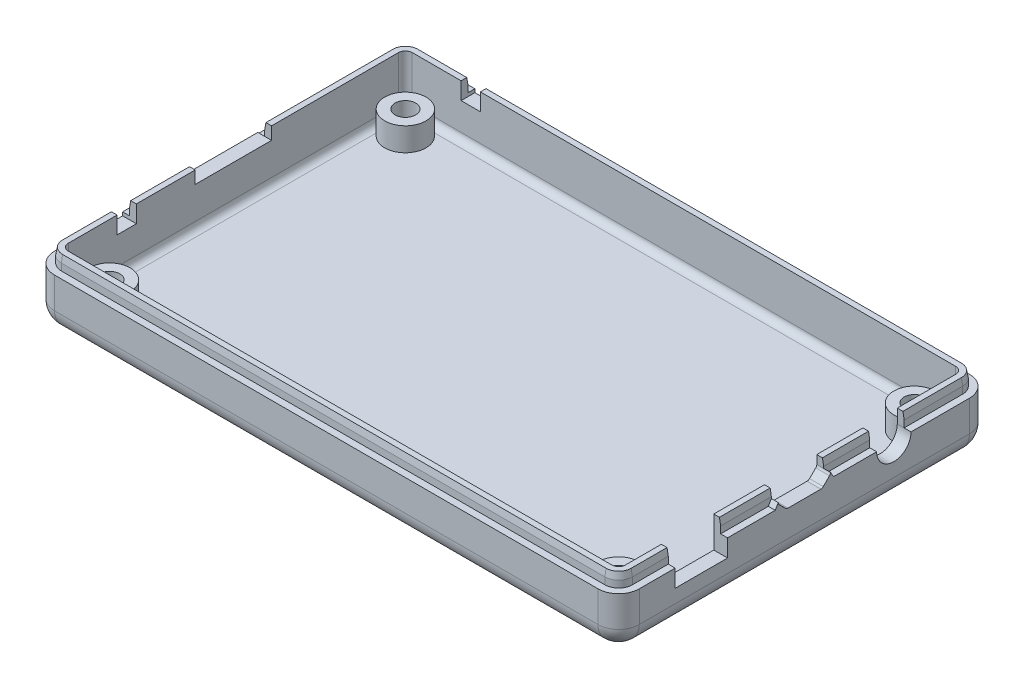
from build123d import *
from OCP.BRepFilletAPI import BRepFilletAPI_MakeChamfer

# Parameters (mm, degrees)
SKETCH_1_W                  = 85
SKETCH_1_H                  = 54
EXTRUDE_576_DEPTH           = 7.5
FILLET_627_R                = 3
CUT_EXTRUDE_1389_DEPTH      = 5.5
FILLET_1467_R               = 1
EXTRUDE_2395_DEPTH          = 2
CHAMFER_2448_SIZE           = 1
CHAMFER_2448_SIZE2          = 0.176326981
SKETCH_16_R                 = 2.5
CUT_EXTRUDE_2683_DEPTH      = 5
SKETCH_19_W                 = 7.62
SKETCH_19_H                 = 5.08
CUT_EXTRUDE_3124_DEPTH      = 10
SKETCH_21_W                 = 11.1
SKETCH_21_H                 = 1.1
CUT_EXTRUDE_2_DEPTH         = 10
SKETCH_22_W                 = 2.8
SKETCH_22_H                 = 1.2
CUT_EXTRUDE_3_DEPTH         = 10
CUT_EXTRUDE_5_DEPTH         = 10
SKETCH_30_W                 = 11.1
SKETCH_30_H                 = 0.725
SKETCH_30_W_2               = 2.8
SKETCH_30_H_2               = 1.3
CUT_EXTRUDE_6_DEPTH         = 1
EXTRUDE_2_DEPTH             = 1
EXTRUDE_3_DEPTH             = 1
CUT_EXTRUDE_START           = -1
SKETCH_31_W                 = 7.6
SKETCH_31_H                 = 0.55
SKETCH_31_W_2               = 5
SKETCH_31_H_2               = 2
CUT_EXTRUDE_7_DEPTH         = 1
SKETCH_32_W                 = 2.8
SKETCH_32_H                 = 1.2
CUT_EXTRUDE_8_DEPTH         = 10
SKETCH_33_W                 = 2.8
SKETCH_33_H                 = 1.3
CUT_EXTRUDE_9_DEPTH         = 2
SKETCH_34_R                 = 3
SKETCH_34_R_2               = 1.5
EXTRUDE_4_DEPTH             = 3.4
PATTERN_LINEAR_1_COUNT      = 2
PATTERN_LINEAR_1_PITCH      = 74
PATTERN_LINEAR_1_COUNT_DIR2 = 2
PATTERN_LINEAR_1_PITCH_DIR2 = 43


with BuildPart() as part:
    # 草图1 → Extrude 576 (new body)
    with BuildSketch(Plane(origin=(0, 0, 0), x_dir=(1, 0, 0), z_dir=(0, 1, 0))):
        Rectangle(SKETCH_1_W, SKETCH_1_H)
    extrude(amount=EXTRUDE_576_DEPTH)

    # Fillet 627
    fillet_627_edges = [part.edges().sort_by_distance(p)[0] for p in [
        (0, 0, 27),
        (-42.5, 0, 0),
        (0, 0, -27),
        (42.5, 0, 0),
        (42.5, 3.75, 27),
        (-42.5, 3.75, 27),
        (-42.5, 3.75, -27),
        (42.5, 3.75, -27),
    ]]
    fillet(fillet_627_edges, radius=FILLET_627_R)

    # 草图14 → Cut-Extrude 1389 (cut)
    with BuildSketch(Plane(origin=(0, 7.5, 0), x_dir=(1, 0, 0), z_dir=(0, 1, 0))):
        with BuildLine():
            Line((-39.5, -25), (39.5, -25))
            ThreePointArc((39.5, -25), (40.207106781, -24.707106781), (40.5, -24))
            Line((40.5, -24), (40.5, 24))
            ThreePointArc((40.5, 24), (40.207106781, 24.707106781), (39.5, 25))
            Line((39.5, 25), (-39.5, 25))
            ThreePointArc((-39.5, 25), (-40.207106781, 24.707106781), (-40.5, 24))
            Line((-40.5, 24), (-40.5, -24))
            ThreePointArc((-40.5, -24), (-40.207106781, -24.707106781), (-39.5, -25))
        make_face()
    extrude(amount=-CUT_EXTRUDE_1389_DEPTH, mode=Mode.SUBTRACT)

    # Fillet 1467
    fillet_1467_edges = [part.edges().sort_by_distance(p)[0] for p in [
        (40.207106781, 2, 24.707106781),
        (0, 2, 25),
        (-40.207106781, 2, 24.707106781),
        (-40.5, 2, 0),
        (-40.207106781, 2, -24.707106781),
        (0, 2, -25),
        (40.207106781, 2, -24.707106781),
        (40.5, 2, 0),
    ]]
    fillet(fillet_1467_edges, radius=FILLET_1467_R)

    # 草图15 → Extrude 2395 (add)
    with BuildSketch(Plane(origin=(0, 7.5, 0), x_dir=(1, 0, 0), z_dir=(0, 1, 0))):
        with BuildLine():
            Line((-39.5, -26), (39.5, -26))
            ThreePointArc((39.5, -26), (40.914213562, -25.414213562), (41.5, -24))
            Line((41.5, -24), (41.5, 24))
            ThreePointArc((41.5, 24), (40.914213562, 25.414213562), (39.5, 26))
            Line((39.5, 26), (-39.5, 26))
            ThreePointArc((-39.5, 26), (-40.914213562, 25.414213562), (-41.5, 24))
            Line((-41.5, 24), (-41.5, -24))
            ThreePointArc((-41.5, -24), (-40.914213562, -25.414213562), (-39.5, -26))
        make_face()
        with BuildLine():
            Line((-39.5, -25), (39.5, -25))
            ThreePointArc((39.5, -25), (40.207106781, -24.707106781), (40.5, -24))
            Line((40.5, -24), (40.5, 24))
            ThreePointArc((40.5, 24), (40.207106781, 24.707106781), (39.5, 25))
            Line((39.5, 25), (-39.5, 25))
            ThreePointArc((-39.5, 25), (-40.207106781, 24.707106781), (-40.5, 24))
            Line((-40.5, 24), (-40.5, -24))
            ThreePointArc((-40.5, -24), (-40.207106781, -24.707106781), (-39.5, -25))
        make_face(mode=Mode.SUBTRACT)
    extrude(amount=EXTRUDE_2395_DEPTH)

    # Chamfer 2448: one chamfer whose edges measure the first distance from different faces: ONE call of the kernel's chamfer builder (chamfer() names one face for all edges)
    chamfer_2448_edges_1 = [part.edges().sort_by_distance(p)[0] for p in [
        (-40.914213562, 9.5, 25.414213562),
    ]]
    chamfer_2448_side_1 = [part.faces().sort_by_distance(p)[0] for p in [
        (-40.914213562, 8.5, 25.414213562),
    ]]
    chamfer_2448_edges_2 = [part.edges().sort_by_distance(p)[0] for p in [
        (0, 9.5, 26),
    ]]
    chamfer_2448_side_2 = [part.faces().sort_by_distance(p)[0] for p in [
        (0, 8.5, 26),
    ]]
    chamfer_2448_edges_3 = [part.edges().sort_by_distance(p)[0] for p in [
        (40.914213562, 9.5, 25.414213562),
    ]]
    chamfer_2448_side_3 = [part.faces().sort_by_distance(p)[0] for p in [
        (40.914213562, 8.5, 25.414213562),
    ]]
    chamfer_2448_edges_4 = [part.edges().sort_by_distance(p)[0] for p in [
        (41.5, 9.5, 0),
    ]]
    chamfer_2448_side_4 = [part.faces().sort_by_distance(p)[0] for p in [
        (41.5, 8.5, 0),
    ]]
    chamfer_2448_edges_5 = [part.edges().sort_by_distance(p)[0] for p in [
        (40.914213562, 9.5, -25.414213562),
    ]]
    chamfer_2448_side_5 = [part.faces().sort_by_distance(p)[0] for p in [
        (40.914213562, 8.5, -25.414213562),
    ]]
    chamfer_2448_edges_6 = [part.edges().sort_by_distance(p)[0] for p in [
        (0, 9.5, -26),
    ]]
    chamfer_2448_side_6 = [part.faces().sort_by_distance(p)[0] for p in [
        (0, 8.5, -26),
    ]]
    chamfer_2448_edges_7 = [part.edges().sort_by_distance(p)[0] for p in [
        (-40.914213562, 9.5, -25.414213562),
    ]]
    chamfer_2448_side_7 = [part.faces().sort_by_distance(p)[0] for p in [
        (-40.914213562, 8.5, -25.414213562),
    ]]
    chamfer_2448_edges_8 = [part.edges().sort_by_distance(p)[0] for p in [
        (-41.5, 9.5, 0),
    ]]
    chamfer_2448_side_8 = [part.faces().sort_by_distance(p)[0] for p in [
        (-41.5, 8.5, 0),
    ]]
    chamfer_2448 = BRepFilletAPI_MakeChamfer(part.part.solid().wrapped)
    for e in chamfer_2448_edges_1:
        chamfer_2448.Add(CHAMFER_2448_SIZE, CHAMFER_2448_SIZE2, e.wrapped, chamfer_2448_side_1[0].wrapped)  # the first distance lies on this face
    for e in chamfer_2448_edges_2:
        chamfer_2448.Add(CHAMFER_2448_SIZE, CHAMFER_2448_SIZE2, e.wrapped, chamfer_2448_side_2[0].wrapped)  # the first distance lies on this face
    for e in chamfer_2448_edges_3:
        chamfer_2448.Add(CHAMFER_2448_SIZE, CHAMFER_2448_SIZE2, e.wrapped, chamfer_2448_side_3[0].wrapped)  # the first distance lies on this face
    for e in chamfer_2448_edges_4:
        chamfer_2448.Add(CHAMFER_2448_SIZE, CHAMFER_2448_SIZE2, e.wrapped, chamfer_2448_side_4[0].wrapped)  # the first distance lies on this face
    for e in chamfer_2448_edges_5:
        chamfer_2448.Add(CHAMFER_2448_SIZE, CHAMFER_2448_SIZE2, e.wrapped, chamfer_2448_side_5[0].wrapped)  # the first distance lies on this face
    for e in chamfer_2448_edges_6:
        chamfer_2448.Add(CHAMFER_2448_SIZE, CHAMFER_2448_SIZE2, e.wrapped, chamfer_2448_side_6[0].wrapped)  # the first distance lies on this face
    for e in chamfer_2448_edges_7:
        chamfer_2448.Add(CHAMFER_2448_SIZE, CHAMFER_2448_SIZE2, e.wrapped, chamfer_2448_side_7[0].wrapped)  # the first distance lies on this face
    for e in chamfer_2448_edges_8:
        chamfer_2448.Add(CHAMFER_2448_SIZE, CHAMFER_2448_SIZE2, e.wrapped, chamfer_2448_side_8[0].wrapped)  # the first distance lies on this face
    add(Compound.cast(chamfer_2448.Shape()), mode=Mode.REPLACE)

    # 草图16 → Cut-Extrude 2683 (cut)
    with BuildSketch(Plane(origin=(42.5, 0, 0), x_dir=(0, 0, -1), z_dir=(1, 0, 0))):
        with Locations((13, 7.5)):
            Circle(SKETCH_16_R)
    extrude(amount=-CUT_EXTRUDE_2683_DEPTH, mode=Mode.SUBTRACT)

    # 草图19 → Cut-Extrude 3124 (cut)
    with BuildSketch(Plane(origin=(42.5, 0, 0), x_dir=(0, 0, -1), z_dir=(1, 0, 0))):
        with Locations((-14.978380782, 7.5)):
            Rectangle(SKETCH_19_W, SKETCH_19_H)
    extrude(amount=-CUT_EXTRUDE_3124_DEPTH, mode=Mode.SUBTRACT)

    # 草图21 → 切除-拉伸2 (cut)
    with BuildSketch(Plane.ZY.offset(42.5)):
        with Locations((0, 8.225)):
            Rectangle(SKETCH_21_W, SKETCH_21_H)
    extrude(amount=-CUT_EXTRUDE_2_DEPTH, mode=Mode.SUBTRACT)

    # 草图22 → 切除-拉伸3 (cut)
    with BuildSketch(Plane.ZY.offset(42.5)):
        with Locations((15.5, 7.6)):
            Rectangle(SKETCH_22_W, SKETCH_22_H)
    extrude(amount=-CUT_EXTRUDE_3_DEPTH, mode=Mode.SUBTRACT)

    # 草图25 → 切除-拉伸5 (cut)
    with BuildSketch(Plane(origin=(42.5, 0, 0), x_dir=(0, 0, -1), z_dir=(1, 0, 0))):
        with BuildLine():
            Line((3.8, 8.257106781), (3.8, 8.95))
            ThreePointArc((3.8, 8.95), (3.653553391, 9.303553391), (3.3, 9.45))
            Line((3.3, 9.45), (-3.3, 9.45))
            ThreePointArc((-3.3, 9.45), (-3.653553391, 9.303553391), (-3.8, 8.95))
            Line((-3.8, 8.95), (-3.8, 8.257106781))
            ThreePointArc((-3.8, 8.257106781), (-3.761939766, 8.065765065), (-3.653553391, 7.903553391))
            Line((-3.653553391, 7.903553391), (-2.746446609, 6.996446609))
            ThreePointArc((-2.746446609, 6.996446609), (-2.584234935, 6.888060234), (-2.392893219, 6.85))
            Line((-2.392893219, 6.85), (2.392893219, 6.85))
            ThreePointArc((2.392893219, 6.85), (2.584234935, 6.888060234), (2.746446609, 6.996446609))
            Line((2.746446609, 6.996446609), (3.653553391, 7.903553391))
            ThreePointArc((3.653553391, 7.903553391), (3.761939766, 8.065765065), (3.8, 8.257106781))
        make_face()
    extrude(amount=-CUT_EXTRUDE_5_DEPTH, mode=Mode.SUBTRACT)

    # 草图30 → 切除-拉伸6 (cut)
    with BuildSketch(Plane.ZY.offset(41.5)):
        with Locations((0, 9.1375)):
            Rectangle(SKETCH_30_W, SKETCH_30_H)
        with Locations((15.5, 8.85)):
            Rectangle(SKETCH_30_W_2, SKETCH_30_H_2)
    extrude(amount=-CUT_EXTRUDE_6_DEPTH, mode=Mode.SUBTRACT)

    # 草图28 → 凸台-拉伸2 (add)
    with BuildSketch(Plane(origin=(41.5, 0, 0), x_dir=(0, 0, -1), z_dir=(1, 0, 0))):
        with BuildLine():
            Line((3.653553391, 7.903553391), (3.25, 7.5))
            Line((3.25, 7.5), (4.237115804, 7.5))
            Line((4.237115804, 7.5), (3.8, 8.257106781))
            ThreePointArc((3.8, 8.257106781), (3.761939766, 8.065765065), (3.653553391, 7.903553391))
        make_face()
        with BuildLine():
            Line((-3.25, 7.5), (-3.653553391, 7.903553391))
            ThreePointArc((-3.653553391, 7.903553391), (-3.761939766, 8.065765065), (-3.8, 8.257106781))
            Line((-3.8, 8.257106781), (-4.237115804, 7.5))
            Line((-4.237115804, 7.5), (-3.25, 7.5))
        make_face()
    extrude(amount=EXTRUDE_2_DEPTH)

    # 草图29 → 凸台-拉伸3 (add)
    with BuildSketch(Plane.ZY.offset(41.5)):
        Polygon((-5.55, 7.675), (-5.651036297, 7.5), (5.651036297, 7.5), (5.55, 7.675), align=None)
    extrude(amount=EXTRUDE_3_DEPTH)

    # 草图31 → 切除-拉伸7 (cut)
    with BuildSketch(Plane(origin=(41.5, 0, 0), x_dir=(0, 0, -1), z_dir=(1, 0, 0)).offset(CUT_EXTRUDE_START)):
        with Locations((0, 9.225)):
            Rectangle(SKETCH_31_W, SKETCH_31_H)
        with Locations((13, 8.5)):
            Rectangle(SKETCH_31_W_2, SKETCH_31_H_2)
    extrude(amount=CUT_EXTRUDE_7_DEPTH, mode=Mode.SUBTRACT)

    # 草图32 → 切除-拉伸8 (cut)
    with BuildSketch(Plane(origin=(0, 0, -27), x_dir=(-1, 0, 0), z_dir=(0, 0, -1))):
        with Locations((31, 7.6)):
            Rectangle(SKETCH_32_W, SKETCH_32_H)
    extrude(amount=-CUT_EXTRUDE_8_DEPTH, mode=Mode.SUBTRACT)

    # 草图33 → 切除-拉伸9 (cut)
    with BuildSketch(Plane(origin=(0, 0, -27), x_dir=(-1, 0, 0), z_dir=(0, 0, -1))):
        with Locations((31, 8.85)):
            Rectangle(SKETCH_33_W, SKETCH_33_H)
    extrude(amount=-CUT_EXTRUDE_9_DEPTH, mode=Mode.SUBTRACT)

    # 草图34 → 凸台-拉伸4 (add)
    with BuildSketch(Plane(origin=(0, 2, 0), x_dir=(1, 0, 0), z_dir=(0, 1, 0))):
        with Locations(Location((-37, 21.5, 0), (0, 0, 123.557309761))):
            Circle(SKETCH_34_R)
        with Locations(Location((-37, 21.5, 0), (0, 0, 270))):
            Circle(SKETCH_34_R_2, mode=Mode.SUBTRACT)
    extrude_4 = extrude(amount=EXTRUDE_4_DEPTH)

    # 阵列(线性)1: Extrude 4 2 × 2
    with Locations(*[(i * PATTERN_LINEAR_1_PITCH, 0, j * PATTERN_LINEAR_1_PITCH_DIR2) for i in range(PATTERN_LINEAR_1_COUNT) for j in range(PATTERN_LINEAR_1_COUNT_DIR2) if (i, j) != (0, 0)]):
        add(extrude_4)


solid = part.part
